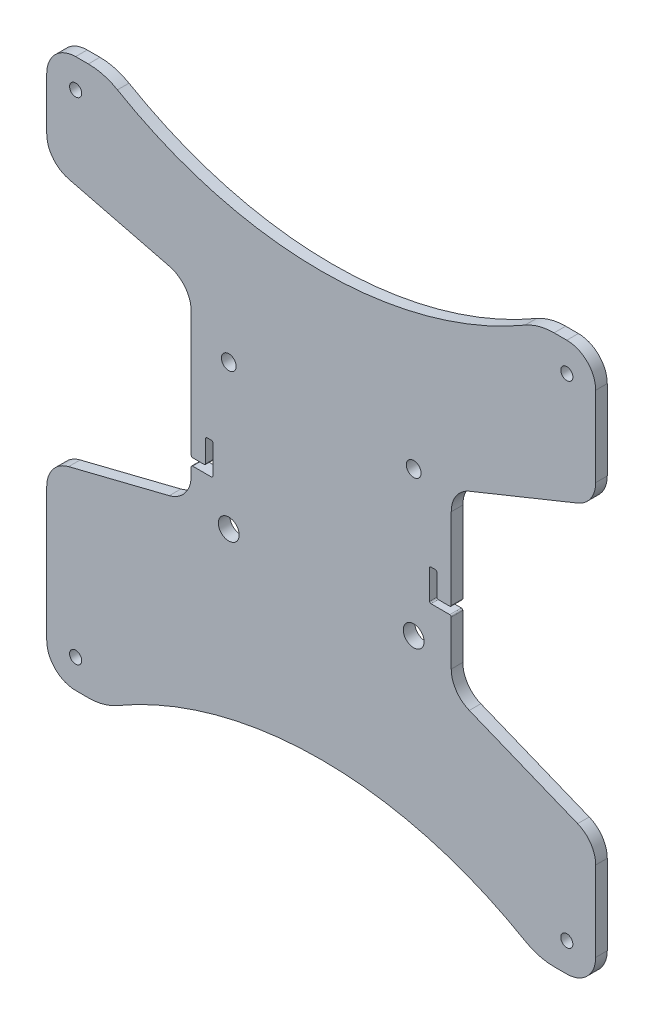
from build123d import *

# Parameters (mm, degrees)
SKETCH1_R           = 2.1
SKETCH1_R_2         = 2.55
SKETCH1_R_3         = 3.6
BOSS_EXTRUDE1_DEPTH = 4


with BuildPart() as part:
    # Sketch1 → Boss-Extrude1 (new body)
    with BuildSketch(Plane(origin=(0, 0, 0), x_dir=(-1, 0, 0), z_dir=(0, 0, -1))):
        with BuildLine():
            Line((87.42535625, -29.106339063), (52.57464375, -20.393660937))
            ThreePointArc((52.57464375, -20.393660937), (47.11794562, -16.84635803), (45, -10.692235936))
            Line((45, -10.692235936), (45, -8))
            ThreePointArc((45, -8), (44.853553391, -7.646446609), (44.5, -7.5))
            Line((44.5, -7.5), (38, -7.5))
            ThreePointArc((38, -7.5), (37.646446609, -7.353553391), (37.5, -7))
            Line((37.5, -7), (37.5, 3))
            ThreePointArc((37.5, 3), (37.646446609, 3.353553391), (38, 3.5))
            Line((38, 3.5), (39.5, 3.5))
            ThreePointArc((39.5, 3.5), (39.853553391, 3.353553391), (40, 3))
            Line((40, 3), (40, -4.5))
            ThreePointArc((40, -4.5), (40.146446609, -4.853553391), (40.5, -5))
            Line((40.5, -5), (44.5, -5))
            ThreePointArc((44.5, -5), (44.853553391, -4.853553391), (45, -4.5))
            Line((45, -4.5), (45, 38.692235936))
            ThreePointArc((45, 38.692235936), (47.11794562, 44.84635803), (52.57464375, 48.393660937))
            Line((52.57464375, 48.393660937), (87.42535625, 57.106339063))
            ThreePointArc((87.42535625, 57.106339063), (92.88205438, 60.65364197), (95, 66.807764064))
            Line((95, 66.807764064), (95, 85))
            ThreePointArc((95, 85), (92.071067812, 92.071067812), (85, 95))
            Line((85, 95), (80.600023778, 95))
            ThreePointArc((80.600023778, 95), (75.38177505, 94.307249421), (70.525020806, 92.276988022))
            ThreePointArc((70.525020806, 92.276988022), (0, 73.215904175), (-70.525020806, 92.276988022))
            ThreePointArc((-70.525020806, 92.276988022), (-75.38177505, 94.307249421), (-80.600023778, 95))
            Line((-80.600023778, 95), (-85, 95))
            ThreePointArc((-85, 95), (-92.071067812, 92.071067812), (-95, 85))
            Line((-95, 85), (-95, 57.30993956))
            ThreePointArc((-95, 57.30993956), (-93.292887614, 51.721736358), (-88.754396995, 48.041471336))
            Line((-88.754396995, 48.041471336), (-51.245603005, 32.847708996))
            ThreePointArc((-51.245603005, 32.847708996), (-46.707112386, 29.167443975), (-45, 23.579240773))
            Line((-45, 23.579240773), (-45, -4.5))
            ThreePointArc((-45, -4.5), (-44.853553391, -4.853553391), (-44.5, -5))
            Line((-44.5, -5), (-40.5, -5))
            ThreePointArc((-40.5, -5), (-40.146446609, -4.853553391), (-40, -4.5))
            Line((-40, -4.5), (-40, 3))
            ThreePointArc((-40, 3), (-39.853553391, 3.353553391), (-39.5, 3.5))
            Line((-39.5, 3.5), (-38, 3.5))
            ThreePointArc((-38, 3.5), (-37.646446609, 3.353553391), (-37.5, 3))
            Line((-37.5, 3), (-37.5, -7))
            ThreePointArc((-37.5, -7), (-37.646446609, -7.353553391), (-38, -7.5))
            Line((-38, -7.5), (-44.5, -7.5))
            ThreePointArc((-44.5, -7.5), (-44.853553391, -7.646446609), (-45, -8))
            Line((-45, -8), (-45, -23.579240773))
            ThreePointArc((-45, -23.579240773), (-46.707112386, -29.167443975), (-51.245603005, -32.847708996))
            Line((-51.245603005, -32.847708996), (-88.754396995, -48.041471336))
            ThreePointArc((-88.754396995, -48.041471336), (-93.292887614, -51.721736358), (-95, -57.30993956))
            Line((-95, -57.30993956), (-95, -85))
            ThreePointArc((-95, -85), (-92.071067812, -92.071067812), (-85, -95))
            Line((-85, -95), (-80.600023778, -95))
            ThreePointArc((-80.600023778, -95), (-75.38177505, -94.307249421), (-70.525020806, -92.276988022))
            ThreePointArc((-70.525020806, -92.276988022), (0, -73.215904175), (70.525020806, -92.276988022))
            ThreePointArc((70.525020806, -92.276988022), (75.38177505, -94.307249421), (80.600023778, -95))
            Line((80.600023778, -95), (85, -95))
            ThreePointArc((85, -95), (92.071067812, -92.071067812), (95, -85))
            Line((95, -85), (95, -38.807764064))
            ThreePointArc((95, -38.807764064), (92.88205438, -32.65364197), (87.42535625, -29.106339063))
        make_face()
        with Locations((-85, -85)):
            Circle(SKETCH1_R, mode=Mode.SUBTRACT)
        with Locations((-85, 85)):
            Circle(SKETCH1_R, mode=Mode.SUBTRACT)
        with Locations((85, 85)):
            Circle(SKETCH1_R, mode=Mode.SUBTRACT)
        with Locations((85, -85)):
            Circle(SKETCH1_R, mode=Mode.SUBTRACT)
        with Locations((32, 29.9)):
            Circle(SKETCH1_R_2, mode=Mode.SUBTRACT)
        with Locations((32, -20.1)):
            Circle(SKETCH1_R_3, mode=Mode.SUBTRACT)
        with Locations((-32, -20.1)):
            Circle(SKETCH1_R_3, mode=Mode.SUBTRACT)
        with Locations((-32, 29.9)):
            Circle(SKETCH1_R_2, mode=Mode.SUBTRACT)
    extrude(amount=-BOSS_EXTRUDE1_DEPTH)


solid = part.part
